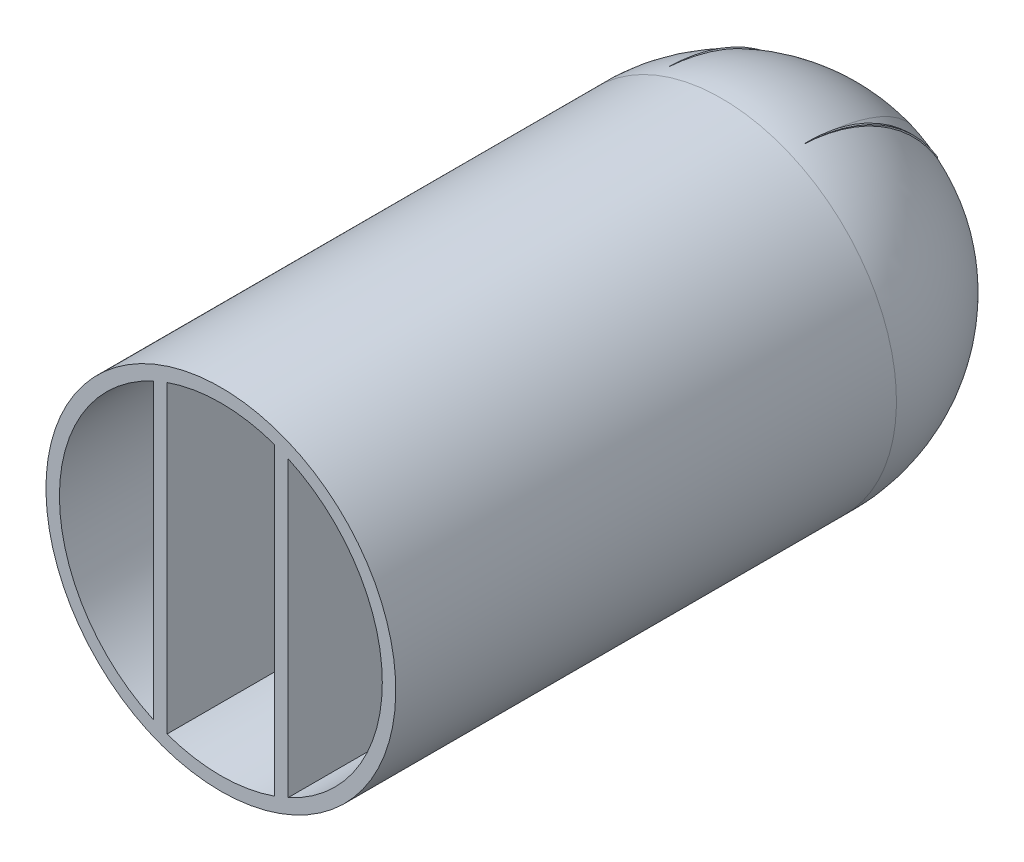
from build123d import *

# Parameters (mm, degrees)
SKETCH1_R               = 2.5
SKETCH1_W               = 41
SKETCH1_H               = 21
BOSS_EXTRUDE1_DEPTH     = 2
SKETCH6_W               = 41
SKETCH6_H               = 21
BOSS_EXTRUDE4_DEPTH     = 2
SKETCH7_W               = 12
SKETCH7_H               = 52.665356288
CUT_EXTRUDE1_DEPTH      = 27.017107748
CUT_EXTRUDE1_DEPTH_BACK = 27.017107748


with BuildPart() as part:
    # Sketch1 → Boss-Extrude1 (new body)
    with BuildSketch(Plane(origin=(0, 0, 0), x_dir=(0, 0, -1), z_dir=(1, 0, 0))):
        with BuildLine():
            Line((-50, -24), (-50, 24))
            Line((-50, 24), (26, 24))
            ThreePointArc((26, 24), (50, 0), (26, -24))
            Line((26, -24), (-50, -24))
        make_face()
        with Locations((36.7, 5)):
            Circle(SKETCH1_R, mode=Mode.SUBTRACT)
        with Locations((36.7, -5)):
            Circle(SKETCH1_R, mode=Mode.SUBTRACT)
        with Locations((-11.3, -5)):
            Circle(SKETCH1_R, mode=Mode.SUBTRACT)
        with Locations((-11.3, 5)):
            Circle(SKETCH1_R, mode=Mode.SUBTRACT)
        with Locations((12.7, 0)):
            Rectangle(SKETCH1_W, SKETCH1_H, mode=Mode.SUBTRACT)
    extrude(amount=BOSS_EXTRUDE1_DEPTH)

    # Sketch4 → Revolve1 (revolve)
    with BuildSketch(Plane.ZY.offset(8)):
        with BuildLine():
            Line((50, 26), (-24.431682486, 26))
            ThreePointArc((-24.431682486, 26), (-43.758091094, 18.779728114), (-52.3, 0))
            Line((-52.3, 0), (-50.3, 0))
            ThreePointArc((-50.3, 0), (-43.118417904, 16.984725201), (-26.064329506, 24))
            Line((-26.064329506, 24), (50, 24))
            Line((50, 24), (50, 26))
        make_face()
    revolve(axis=Axis((-8, 0, -50), (0, 0, 1)))

    # Sketch6 → Boss-Extrude4 (add)
    with BuildSketch(Plane.ZY.offset(16)):
        with BuildLine():
            Line((-26, 24), (50, 24))
            Line((50, 24), (50, -24))
            Line((50, -24), (-26, -24))
            ThreePointArc((-26, -24), (-50, 0), (-26, 24))
        make_face()
        with Locations((-12.7, 0)):
            Rectangle(SKETCH6_W, SKETCH6_H, mode=Mode.SUBTRACT)
    extrude(amount=BOSS_EXTRUDE4_DEPTH)

    # Sketch7 → Cut-Extrude1 (cut, two sides)
    with BuildSketch(Plane.ZY.offset(8)) as cut_extrude1_sk:
        with Locations((-52.5, 0)):
            Rectangle(SKETCH7_W, SKETCH7_H)
    extrude(amount=CUT_EXTRUDE1_DEPTH, mode=Mode.SUBTRACT)
    extrude(cut_extrude1_sk.sketch, amount=-CUT_EXTRUDE1_DEPTH_BACK, mode=Mode.SUBTRACT)


solid = part.part
